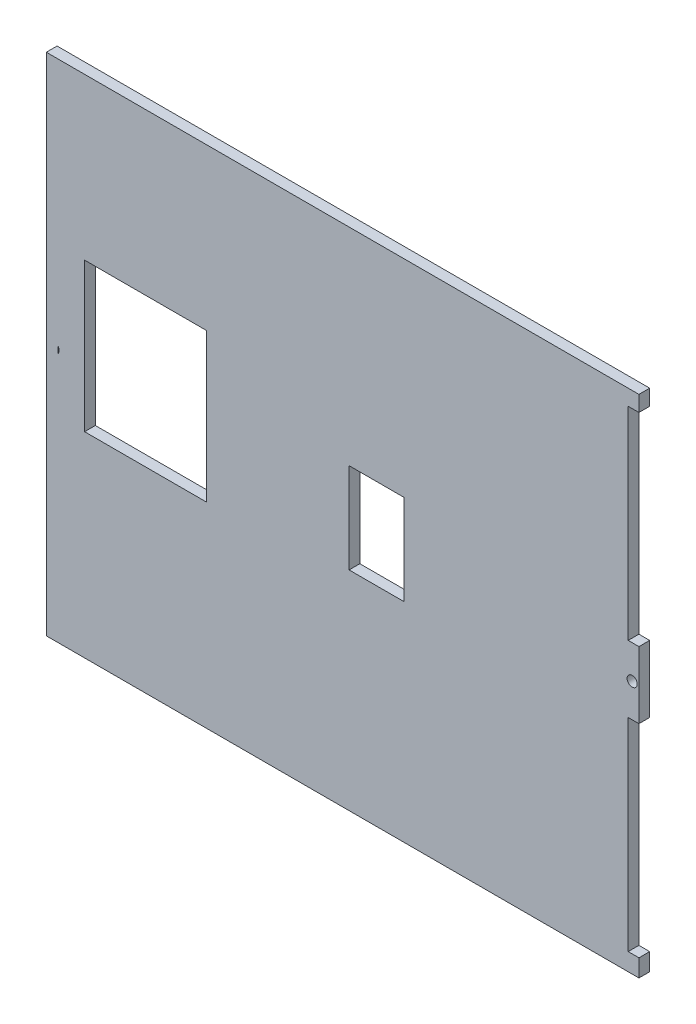
from build123d import *

# Parameters (mm, degrees)
SKETCH1_W           = 175
SKETCH1_H           = 139.7
BOSS_EXTRUDE1_DEPTH = 3.18
SKETCH2_R           = 1.5
SKETCH2_W           = 3.18
SKETCH2_H           = 59.975
CUT_EXTRUDE1_DEPTH  = 4.18
SKETCH3_R           = 1.59
CUT_EXTRUDE2_DEPTH  = 4.18
SKETCH4_R           = 1.59
CUT_EXTRUDE3_DEPTH  = 4.18
SKETCH5_W           = 91.926224914
SKETCH5_H           = 123.656630911
BOSS_EXTRUDE2_DEPTH = 3.18
SKETCH6_W           = 3.18
SKETCH6_H           = 19.75
CUT_EXTRUDE4_DEPTH  = 4.18
SKETCH8_W           = 25.560381265
SKETCH8_H           = 19.67928192
BOSS_EXTRUDE3_DEPTH = 3.18
SKETCH10_W          = 20
SKETCH10_H          = 2.468001363
BOSS_EXTRUDE4_DEPTH = 3.18
CUT_EXTRUDE5_DEPTH  = 4.18
SKETCH12_W          = 36.012104279
SKETCH12_H          = 43.960205632
CUT_EXTRUDE6_DEPTH  = 4.18
SKETCH13_W          = 16.174082381
SKETCH13_H          = 26.705141904
CUT_EXTRUDE7_DEPTH  = 4.18
SKETCH16_W          = 18.884338216
SKETCH16_H          = 121.056150973
SKETCH16_W_2        = 10.857087527
SKETCH16_H_2        = 35.437593219
SKETCH16_W_3        = 28.428801023
SKETCH16_H_3        = 14.001351757
SKETCH16_W_4        = 22.576937907
SKETCH16_H_4        = 16.729537969
BOSS_EXTRUDE6_DEPTH = 3.18
BOSS_EXTRUDE7_DEPTH = 3.18


with BuildPart() as part:
    # Sketch1 → Boss-Extrude1 (new body)
    with BuildSketch(Plane.XY):
        Rectangle(SKETCH1_W, SKETCH1_H)
    extrude(amount=BOSS_EXTRUDE1_DEPTH)

    # Sketch2 → Cut-Extrude1 (cut, through all)
    with BuildSketch(Plane.XY.offset(3.18)):
        with Locations((-85.5, 0)):
            Circle(SKETCH2_R)
        with Locations((85.5, 0)):
            Circle(SKETCH2_R)
        Polygon((-10, 69.85), (10, 69.85), (10, 66.67), (1.5, 66.67), (1.5, 62.67), (3.5, 62.67), (3.5, 59.67), (1.5, 59.67), (1.5, 56.67), (-1.5, 56.67), (-1.5, 59.67), (-3.5, 59.67), (-3.5, 62.67), (-1.5, 62.67), (-1.5, 66.67), (-10, 66.67), align=None)
        Polygon((-10, -69.85), (-10, -66.67), (-1.5, -66.67), (-1.5, -62.67), (-3.5, -62.67), (-3.5, -59.67), (-1.5, -59.67), (-1.5, -56.67), (1.5, -56.67), (1.5, -59.67), (3.5, -59.67), (3.5, -62.67), (1.5, -62.67), (1.5, -66.67), (10, -66.67), (10, -69.85), align=None)
        with Locations((-85.91, 39.8625)):
            Rectangle(SKETCH2_W, SKETCH2_H)
        with Locations((-85.91, -39.8625)):
            Rectangle(SKETCH2_W, SKETCH2_H)
        with Locations((85.91, -39.8625)):
            Rectangle(SKETCH2_W, SKETCH2_H)
        with Locations((85.91, 39.8625)):
            Rectangle(SKETCH2_W, SKETCH2_H)
        Polygon((-28.854904074, -66.67), (-20.334061159, -66.67), (-20.334061159, -69.85), (-40.334061159, -69.85), (-40.334061159, -66.67), (-31.854904074, -66.67), (-31.854904074, -62.67), (-33.77295002, -62.67), (-33.77295002, -59.67), (-31.854904074, -59.67), (-31.854904074, -56.85), (-28.854904074, -56.85), (-28.854904074, -59.67), (-26.77295002, -59.67), (-26.77295002, -62.67), (-28.854904074, -62.67), align=None)
    extrude(amount=-CUT_EXTRUDE1_DEPTH, mode=Mode.SUBTRACT)

    # Sketch3 → Cut-Extrude2 (cut, through all)
    with BuildSketch(Plane(origin=(0, 0, 0), x_dir=(-1, 0, 0), z_dir=(0, 0, -1))):
        with Locations((-35.67127699, -47.963396943)):
            Circle(SKETCH3_R)
        with Locations((-35.67127699, -30.777287406)):
            Circle(SKETCH3_R)
    extrude(amount=-CUT_EXTRUDE2_DEPTH, mode=Mode.SUBTRACT)

    # Sketch4 → Cut-Extrude3 (cut, through all)
    with BuildSketch(Plane(origin=(0, 0, 0), x_dir=(-1, 0, 0), z_dir=(0, 0, -1))):
        with Locations((-34.750723073, 53.780323187)):
            Circle(SKETCH4_R)
        with Locations((-34.750723073, 36.59421365)):
            Circle(SKETCH4_R)
        with Locations((36.249784221, 53.780323187)):
            Circle(SKETCH4_R)
        with Locations((36.249784221, 36.59421365)):
            Circle(SKETCH4_R)
        with Locations((35.983928162, -30.777287406)):
            Circle(SKETCH4_R)
        with Locations((35.983928162, -47.963396943)):
            Circle(SKETCH4_R)
        with Locations((-35.67127699, -30.777287406)):
            Circle(SKETCH4_R)
        with Locations((-35.67127699, -47.963396943)):
            Circle(SKETCH4_R)
    extrude(amount=-CUT_EXTRUDE3_DEPTH, mode=Mode.SUBTRACT)

    # Sketch5 → Boss-Extrude2 (add)
    with BuildSketch(Plane.XY.offset(3.18)):
        with Locations((-0.563564665, 5.553683182)):
            Rectangle(SKETCH5_W, SKETCH5_H)
    extrude(amount=-BOSS_EXTRUDE2_DEPTH)

    # Sketch6 → Cut-Extrude4 (cut, through all)
    with BuildSketch(Plane(origin=(0, 0, 0), x_dir=(-1, 0, 0), z_dir=(0, 0, -1))):
        with Locations((-25.21, 0.03599429)):
            Rectangle(SKETCH6_W, SKETCH6_H)
        with Locations((13.073612417, 0)):
            Rectangle(SKETCH6_W, SKETCH6_H)
    extrude(amount=-CUT_EXTRUDE4_DEPTH, mode=Mode.SUBTRACT)

    # Sketch8 → Boss-Extrude3 (add)
    with BuildSketch(Plane(origin=(0, 0, 0), x_dir=(-1, 0, 0), z_dir=(0, 0, -1))):
        with Locations((-2.780190633, -60.01035904)):
            Rectangle(SKETCH8_W, SKETCH8_H)
    extrude(amount=-BOSS_EXTRUDE3_DEPTH)

    # Sketch10 → Boss-Extrude4 (add)
    with BuildSketch(Plane(origin=(0, 0, 0), x_dir=(-1, 0, 0), z_dir=(0, 0, -1))):
        with Locations((0, 68.615999319)):
            Rectangle(SKETCH10_W, SKETCH10_H)
    extrude(amount=-BOSS_EXTRUDE4_DEPTH)

    # Sketch11 → Cut-Extrude5 (cut, through all)
    with BuildSketch(Plane(origin=(0, 0, 0), x_dir=(-1, 0, 0), z_dir=(0, 0, -1))):
        Polygon((20.793148035, 66.67), (29.479057969, 66.67), (29.479057969, 62.67), (27.293148035, 62.67), (27.293148035, 59.67), (29.479057969, 59.67), (29.479057969, 56.85), (32.479057969, 56.85), (32.479057969, 59.67), (34.293148035, 59.67), (34.293148035, 62.67), (32.479057969, 62.67), (32.479057969, 66.67), (40.793148035, 66.67), (40.793148035, 69.85), (20.793148035, 69.85), align=None)
    extrude(amount=-CUT_EXTRUDE5_DEPTH, mode=Mode.SUBTRACT)

    # Sketch12 → Cut-Extrude6 (cut, through all)
    with BuildSketch(Plane(origin=(0, 0, 0), x_dir=(-1, 0, 0), z_dir=(0, 0, -1))):
        with Locations((58.477018613, 4.914539536)):
            Rectangle(SKETCH12_W, SKETCH12_H)
    extrude(amount=-CUT_EXTRUDE6_DEPTH, mode=Mode.SUBTRACT)

    # Sketch13 → Cut-Extrude7 (cut, through all)
    with BuildSketch(Plane(origin=(0, 0, 0), x_dir=(-1, 0, 0), z_dir=(0, 0, -1))):
        with Locations((-9.848843291, 0)):
            Rectangle(SKETCH13_W, SKETCH13_H)
    extrude(amount=-CUT_EXTRUDE7_DEPTH, mode=Mode.SUBTRACT)

    # Sketch16 → Boss-Extrude6 (add)
    with BuildSketch(Plane(origin=(0, 0, 0), x_dir=(-1, 0, 0), z_dir=(0, 0, -1))):
        with Locations((-31.859595144, -9.321924514)):
            Rectangle(SKETCH16_W, SKETCH16_H)
        with Locations((12.113243242, -1.915189585)):
            Rectangle(SKETCH16_W_2, SKETCH16_H_2)
        with Locations((31.756187516, -62.849324122)):
            Rectangle(SKETCH16_W_3, SKETCH16_H_3)
        with Locations((32.081616989, 61.485231016)):
            Rectangle(SKETCH16_W_4, SKETCH16_H_4)
    extrude(amount=-BOSS_EXTRUDE6_DEPTH)

    # Sketch17 → Boss-Extrude7 (add)
    with BuildSketch(Plane(origin=(0, 0, 0), x_dir=(-1, 0, 0), z_dir=(0, 0, -1))):
        Polygon((-87.5, -69.85), (84.32, -69.85), (84.32, 69.85), (-87.5, 69.85), (-87.5, 74.493800826), (84.32, 74.493800826), (87.808220565, 74.493800826), (87.808220565, -69.85), (87.808220565, -75.025003811), (84.32, -75.025003811), (-87.5, -75.025003811), align=None)
    extrude(amount=-BOSS_EXTRUDE7_DEPTH)


solid = part.part
